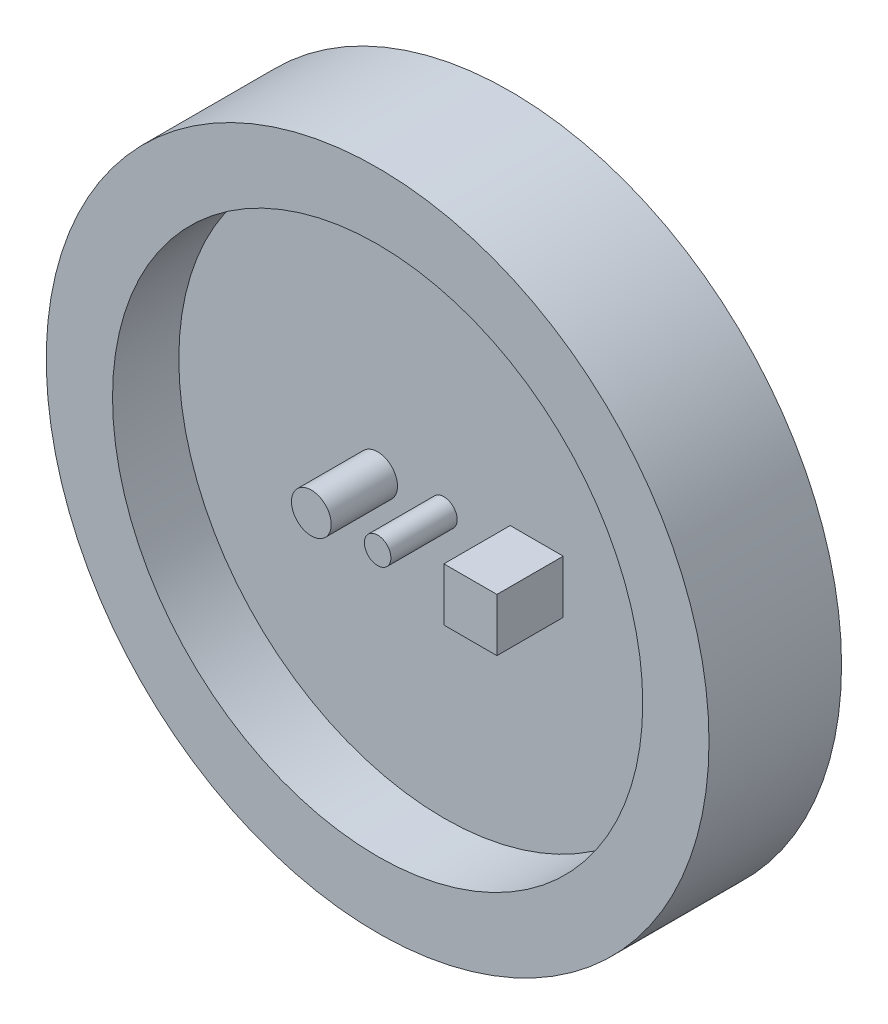
from build123d import *

# Parameters (mm, degrees)
SKETCH1_R           = 25
BOSS_EXTRUDE1_DEPTH = 10
SHELL3_T            = -5
SKETCH3_R           = 1.5
SKETCH3_R_2         = 1
SKETCH3_W           = 4
SKETCH3_H           = 4
BOSS_EXTRUDE2_DEPTH = 5


with BuildPart() as part:
    # Sketch1 → Boss-Extrude1 (new body)
    with BuildSketch(Plane.XY):
        Circle(SKETCH1_R)
    extrude(amount=BOSS_EXTRUDE1_DEPTH)

    # Shell3
    shell3_openings = [part.faces().sort_by_distance(p)[0] for p in [
        (0, 0, 10),
    ]]
    offset(amount=SHELL3_T, openings=shell3_openings, kind=Kind.INTERSECTION)

    # Sketch3 → Boss-Extrude2 (add)
    with BuildSketch(Plane.XY.offset(5)):
        with Locations((-5, -0.061087675)):
            Circle(SKETCH3_R)
        Circle(SKETCH3_R_2)
        with Locations((7, -0.381193265)):
            Rectangle(SKETCH3_W, SKETCH3_H)
    extrude(amount=BOSS_EXTRUDE2_DEPTH)


solid = part.part
